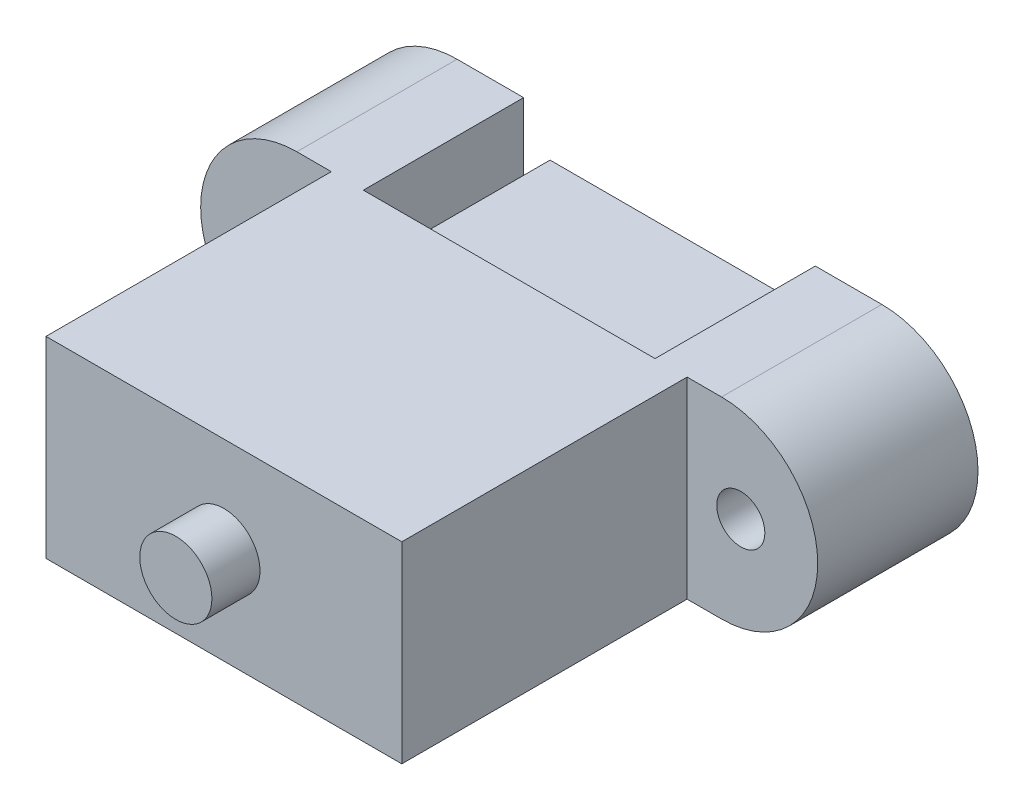
from build123d import *

# Parameters (mm, degrees)
CROQUIS1_R                = 1.5
SALIENTE_EXTRUIR1_DEPTH   = 10
SALIENTE_EXTRUIR1_2_DEPTH = 10
CROQUIS2_W                = 22.2
CROQUIS2_H                = 12
SALIENTE_EXTRUIR2_DEPTH   = 17.8
CROQUIS3_R                = 2.25
SALIENTE_EXTRUIR3_DEPTH   = 3
CROQUIS4_W                = 14.9
CROQUIS4_H                = 6.9
SALIENTE_EXTRUIR4_DEPTH   = 10
CROQUIS5_W                = 12.9
CROQUIS5_H                = 4.9
CROQUIS5_W_2              = 10.8
CROQUIS5_H_2              = 1.83
CORTAR_EXTRUIR1_DEPTH     = 10.5


with BuildPart() as part:
    # Croquis1 → Saliente-Extruir1 (new body)
    with BuildSketch(Plane.XY):
        with BuildLine():
            Line((-9.1, 6), (-9.1, -6))
            Line((-9.1, -6), (-13.25, -6))
            ThreePointArc((-13.25, -6), (-19.25, 0), (-13.25, 6))
            Line((-13.25, 6), (-9.1, 6))
        make_face()
        with Locations((-14.45, 0)):
            Circle(CROQUIS1_R, mode=Mode.SUBTRACT)
    extrude(amount=SALIENTE_EXTRUIR1_DEPTH)



with BuildPart() as body_2:
    # Croquis1 → Saliente-Extruir1 2 (new body)
    with BuildSketch(Plane.XY):
        with BuildLine():
            Line((9.1, 6), (9.1, -6))
            Line((9.1, -6), (13.25, -6))
            ThreePointArc((13.25, -6), (19.25, 0), (13.25, 6))
            Line((13.25, 6), (9.1, 6))
        make_face()
        with Locations((14.45, 0)):
            Circle(CROQUIS1_R, mode=Mode.SUBTRACT)
    extrude(amount=SALIENTE_EXTRUIR1_2_DEPTH)


with BuildPart() as part_1:
    add(part.part)

    add(body_2.part)  # Saliente-Extruir2 merges body 2
    # Croquis2 → Saliente-Extruir2 (add)
    with BuildSketch(Plane.XY.offset(10)):
        Rectangle(CROQUIS2_W, CROQUIS2_H)
    extrude(amount=SALIENTE_EXTRUIR2_DEPTH)

    # Croquis3 → Saliente-Extruir3 (add)
    with BuildSketch(Plane.XY.offset(27.8)):
        Circle(CROQUIS3_R)
    extrude(amount=SALIENTE_EXTRUIR3_DEPTH)

    # Croquis4 → Saliente-Extruir4 (add)
    with BuildSketch(Plane(origin=(0, 0, 10), x_dir=(-1, 0, 0), z_dir=(0, 0, -1))):
        Rectangle(CROQUIS4_W, CROQUIS4_H)
    extrude(amount=SALIENTE_EXTRUIR4_DEPTH)

    # Croquis5 → Cortar-Extruir1 (cut)
    with BuildSketch(Plane(origin=(0, 0, 0), x_dir=(-1, 0, 0), z_dir=(0, 0, -1))):
        Rectangle(CROQUIS5_W, CROQUIS5_H)
        with Locations((0, 0.915)):
            Rectangle(CROQUIS5_W_2, CROQUIS5_H_2, mode=Mode.SUBTRACT)
    extrude(amount=-CORTAR_EXTRUIR1_DEPTH, mode=Mode.SUBTRACT)


solid = part_1.part
